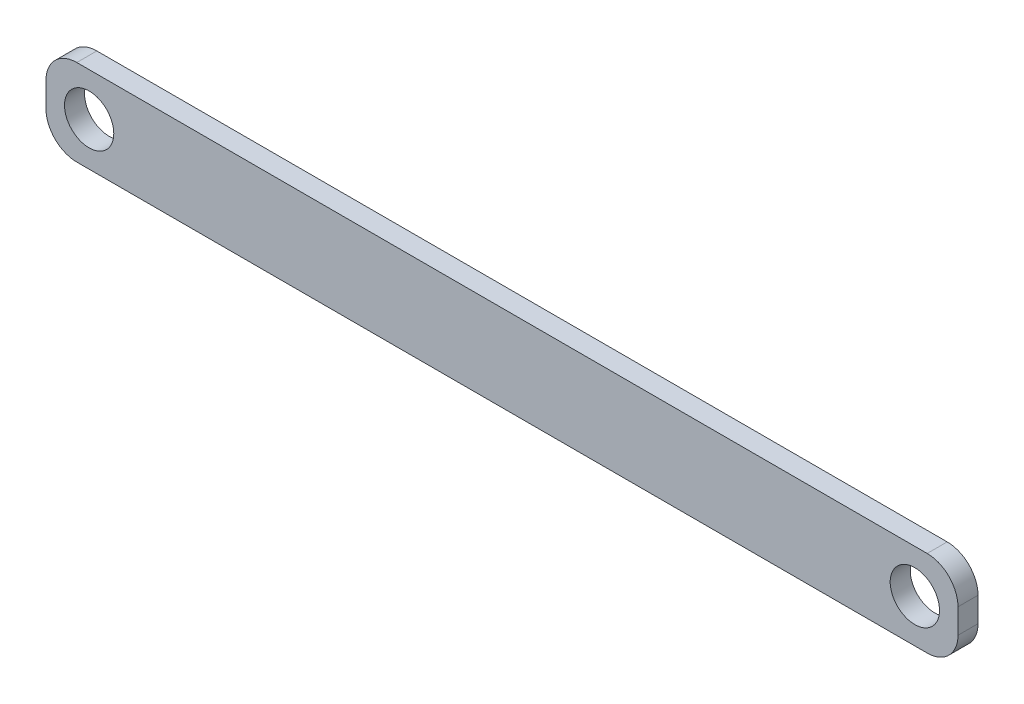
from build123d import *

# Parameters (mm, degrees)
SKETCH2_W           = 296
SKETCH2_H           = 28
SKETCH2_R           = 8
BOSS_EXTRUDE1_DEPTH = 6.5
FILLET1_R           = 10


with BuildPart() as part:
    # Sketch2 → Boss-Extrude1 (new body)
    with BuildSketch(Plane.XY):
        Rectangle(SKETCH2_W, SKETCH2_H)
        with Locations((-134, 0)):
            Circle(SKETCH2_R, mode=Mode.SUBTRACT)
        with Locations((134, 0)):
            Circle(SKETCH2_R, mode=Mode.SUBTRACT)
    extrude(amount=BOSS_EXTRUDE1_DEPTH)

    # Fillet1
    fillet1_edges = [part.edges().sort_by_distance(p)[0] for p in [
        (148, -14, 3.25),
        (-148, -14, 3.25),
        (-148, 14, 3.25),
        (148, 14, 3.25),
    ]]
    fillet(fillet1_edges, radius=FILLET1_R)


solid = part.part
